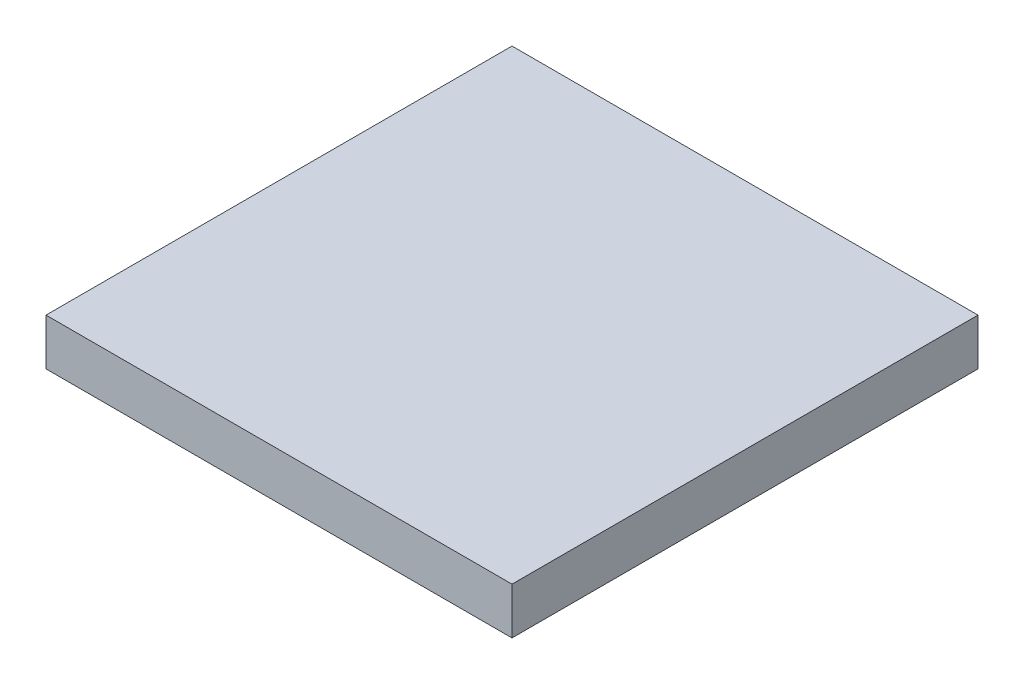
from build123d import *

# Parameters (mm, degrees)
SKETCH1_W           = 5
SKETCH1_H           = 5
BOSS_EXTRUDE1_DEPTH = 0.5


with BuildPart() as part:
    # Sketch1 → Boss-Extrude1 (new body)
    with BuildSketch(Plane(origin=(0, 0, 0), x_dir=(1, 0, 0), z_dir=(0, 1, 0))):
        Rectangle(SKETCH1_W, SKETCH1_H)
    extrude(amount=BOSS_EXTRUDE1_DEPTH)


solid = part.part
